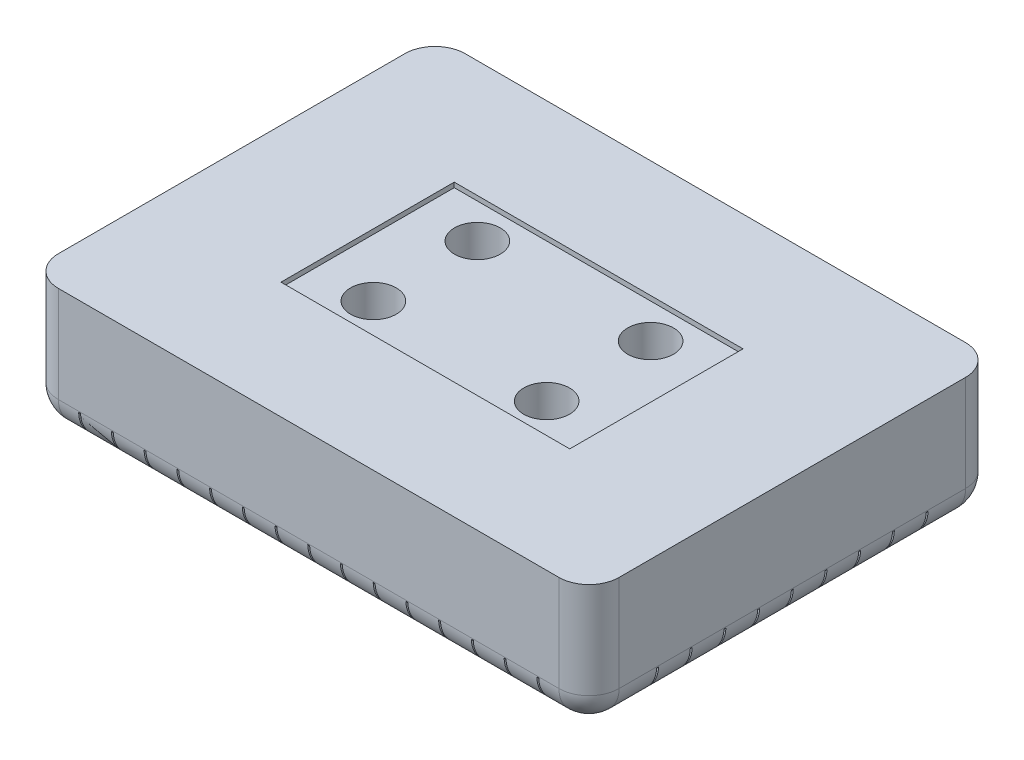
from build123d import *

# Parameters (mm, degrees)
SKETCH1_W             = 739.775
SKETCH1_H             = 536.575
BOSS_EXTRUDE1_DEPTH   = 166.6875
FILLET1_R             = 39.7002
CUT_EXTRUDE1_DEPTH    = 1.27
LPATTERN1_COUNT       = 8
LPATTERN1_PITCH       = 43.18
LPATTERN1_COL_COUNT   = 8
LPATTERN1_COL_PITCH   = 43.18
MIRROR1_COPY_1_DEPTH  = 1.27
MIRROR1_COPY_2_DEPTH  = 1.27
MIRROR1_COPY_3_DEPTH  = 1.27
MIRROR1_COPY_4_DEPTH  = 1.27
MIRROR1_COPY_5_DEPTH  = 1.27
MIRROR1_COPY_6_DEPTH  = 1.27
MIRROR1_COPY_7_DEPTH  = 1.27
MIRROR1_COPY_8_DEPTH  = 1.27
MIRROR1_COPY_9_DEPTH  = 1.27
MIRROR1_COPY_10_DEPTH = 1.27
MIRROR1_COPY_11_DEPTH = 1.27
MIRROR1_COPY_12_DEPTH = 1.27
MIRROR1_COPY_13_DEPTH = 1.27
MIRROR1_COPY_14_DEPTH = 1.27
CUT_EXTRUDE2_DEPTH    = 1.27
LPATTERN2_COUNT       = 5
LPATTERN2_PITCH       = 44.45
LPATTERN2_COL_COUNT   = 5
LPATTERN2_COL_PITCH   = 44.45
MIRROR2_COPY_1_DEPTH  = 1.27
MIRROR2_COPY_2_DEPTH  = 1.27
MIRROR2_COPY_3_DEPTH  = 1.27
MIRROR2_COPY_4_DEPTH  = 1.27
MIRROR2_COPY_5_DEPTH  = 1.27
MIRROR2_COPY_6_DEPTH  = 1.27
MIRROR2_COPY_7_DEPTH  = 1.27
MIRROR2_COPY_8_DEPTH  = 1.27
SKETCH4_R             = 30.1625
CUT_EXTRUDE3_DEPTH    = 167.6875
SKETCH5_W             = 381
SKETCH5_H             = 228.6
CUT_EXTRUDE4_DEPTH    = 6.35


with BuildPart() as part:
    # Sketch1 → Boss-Extrude1 (new body)
    with BuildSketch(Plane(origin=(0, 0, 0), x_dir=(1, 0, 0), z_dir=(0, 1, 0))):
        Rectangle(SKETCH1_W, SKETCH1_H)
    extrude(amount=BOSS_EXTRUDE1_DEPTH)

    # Fillet1
    fillet1_edges = [part.edges().sort_by_distance(p)[0] for p in [
        (0, 0, -268.2875),
        (369.8875, 0, 0),
        (0, 0, 268.2875),
        (-369.8875, 0, 0),
        (-369.8875, 83.34375, -268.2875),
        (369.8875, 83.34375, -268.2875),
        (369.8875, 83.34375, 268.2875),
        (-369.8875, 83.34375, 268.2875),
    ]]
    fillet(fillet1_edges, radius=FILLET1_R)

    # Sketch2 → Cut-Extrude1 (cut, symmetric)
    with BuildSketch(Plane(origin=(0, 0, 0), x_dir=(0, 0, -1), z_dir=(1, 0, 0))):
        with BuildLine():
            Line((279.4, 52.3875), (228.6, -11.1125))
            ThreePointArc((228.6, -11.1125), (264.521024484, 3.766475516), (279.4, 39.6875))
            Line((279.4, 39.6875), (279.4, 52.3875))
        make_face()
    cut_extrude1 = extrude(amount=CUT_EXTRUDE1_DEPTH, both=True, mode=Mode.SUBTRACT)

    # LPattern1: Cut-Extrude1 ×8
    with Locations(*[(i * LPATTERN1_PITCH, 0, 0) for i in range(1, LPATTERN1_COUNT)]):
        add(cut_extrude1, mode=Mode.SUBTRACT)

    # LPattern1 col: Cut-Extrude1 ×8
    with Locations(*[(-i * LPATTERN1_COL_PITCH, 0, 0) for i in range(1, LPATTERN1_COL_COUNT)]):
        add(cut_extrude1, mode=Mode.SUBTRACT)

    # Mirror1: Cut-Extrude1 across plane
    add(cut_extrude1.mirror(Plane.XY), mode=Mode.SUBTRACT)

    # Mirror1 copy 1 sketch → Mirror1 copy 1 (cut, symmetric)
    with BuildSketch(Plane(origin=(43.18, 0, 0), x_dir=(0, 0, 1), z_dir=(1, 0, 0))):
        with BuildLine():
            Line((279.4, -52.3875), (228.6, 11.1125))
            ThreePointArc((228.6, 11.1125), (264.521024484, -3.766475516), (279.4, -39.6875))
            Line((279.4, -39.6875), (279.4, -52.3875))
        make_face()
    extrude(amount=MIRROR1_COPY_1_DEPTH, both=True, mode=Mode.SUBTRACT)

    # Mirror1 copy 2 sketch → Mirror1 copy 2 (cut, symmetric)
    with BuildSketch(Plane(origin=(86.36, 0, 0), x_dir=(0, 0, 1), z_dir=(1, 0, 0))):
        with BuildLine():
            Line((279.4, -52.3875), (228.6, 11.1125))
            ThreePointArc((228.6, 11.1125), (264.521024484, -3.766475516), (279.4, -39.6875))
            Line((279.4, -39.6875), (279.4, -52.3875))
        make_face()
    extrude(amount=MIRROR1_COPY_2_DEPTH, both=True, mode=Mode.SUBTRACT)

    # Mirror1 copy 3 sketch → Mirror1 copy 3 (cut, symmetric)
    with BuildSketch(Plane(origin=(129.54, 0, 0), x_dir=(0, 0, 1), z_dir=(1, 0, 0))):
        with BuildLine():
            Line((279.4, -52.3875), (228.6, 11.1125))
            ThreePointArc((228.6, 11.1125), (264.521024484, -3.766475516), (279.4, -39.6875))
            Line((279.4, -39.6875), (279.4, -52.3875))
        make_face()
    extrude(amount=MIRROR1_COPY_3_DEPTH, both=True, mode=Mode.SUBTRACT)

    # Mirror1 copy 4 sketch → Mirror1 copy 4 (cut, symmetric)
    with BuildSketch(Plane(origin=(172.72, 0, 0), x_dir=(0, 0, 1), z_dir=(1, 0, 0))):
        with BuildLine():
            Line((279.4, -52.3875), (228.6, 11.1125))
            ThreePointArc((228.6, 11.1125), (264.521024484, -3.766475516), (279.4, -39.6875))
            Line((279.4, -39.6875), (279.4, -52.3875))
        make_face()
    extrude(amount=MIRROR1_COPY_4_DEPTH, both=True, mode=Mode.SUBTRACT)

    # Mirror1 copy 5 sketch → Mirror1 copy 5 (cut, symmetric)
    with BuildSketch(Plane(origin=(215.9, 0, 0), x_dir=(0, 0, 1), z_dir=(1, 0, 0))):
        with BuildLine():
            Line((279.4, -52.3875), (228.6, 11.1125))
            ThreePointArc((228.6, 11.1125), (264.521024484, -3.766475516), (279.4, -39.6875))
            Line((279.4, -39.6875), (279.4, -52.3875))
        make_face()
    extrude(amount=MIRROR1_COPY_5_DEPTH, both=True, mode=Mode.SUBTRACT)

    # Mirror1 copy 6 sketch → Mirror1 copy 6 (cut, symmetric)
    with BuildSketch(Plane(origin=(259.08, 0, 0), x_dir=(0, 0, 1), z_dir=(1, 0, 0))):
        with BuildLine():
            Line((279.4, -52.3875), (228.6, 11.1125))
            ThreePointArc((228.6, 11.1125), (264.521024484, -3.766475516), (279.4, -39.6875))
            Line((279.4, -39.6875), (279.4, -52.3875))
        make_face()
    extrude(amount=MIRROR1_COPY_6_DEPTH, both=True, mode=Mode.SUBTRACT)

    # Mirror1 copy 7 sketch → Mirror1 copy 7 (cut, symmetric)
    with BuildSketch(Plane(origin=(302.26, 0, 0), x_dir=(0, 0, 1), z_dir=(1, 0, 0))):
        with BuildLine():
            Line((279.4, -52.3875), (228.6, 11.1125))
            ThreePointArc((228.6, 11.1125), (264.521024484, -3.766475516), (279.4, -39.6875))
            Line((279.4, -39.6875), (279.4, -52.3875))
        make_face()
    extrude(amount=MIRROR1_COPY_7_DEPTH, both=True, mode=Mode.SUBTRACT)

    # Mirror1 copy 8 sketch → Mirror1 copy 8 (cut, symmetric)
    with BuildSketch(Plane(origin=(-43.18, 0, 0), x_dir=(0, 0, 1), z_dir=(1, 0, 0))):
        with BuildLine():
            Line((279.4, -52.3875), (228.6, 11.1125))
            ThreePointArc((228.6, 11.1125), (264.521024484, -3.766475516), (279.4, -39.6875))
            Line((279.4, -39.6875), (279.4, -52.3875))
        make_face()
    extrude(amount=MIRROR1_COPY_8_DEPTH, both=True, mode=Mode.SUBTRACT)

    # Mirror1 copy 9 sketch → Mirror1 copy 9 (cut, symmetric)
    with BuildSketch(Plane(origin=(-86.36, 0, 0), x_dir=(0, 0, 1), z_dir=(1, 0, 0))):
        with BuildLine():
            Line((279.4, -52.3875), (228.6, 11.1125))
            ThreePointArc((228.6, 11.1125), (264.521024484, -3.766475516), (279.4, -39.6875))
            Line((279.4, -39.6875), (279.4, -52.3875))
        make_face()
    extrude(amount=MIRROR1_COPY_9_DEPTH, both=True, mode=Mode.SUBTRACT)

    # Mirror1 copy 10 sketch → Mirror1 copy 10 (cut, symmetric)
    with BuildSketch(Plane(origin=(-129.54, 0, 0), x_dir=(0, 0, 1), z_dir=(1, 0, 0))):
        with BuildLine():
            Line((279.4, -52.3875), (228.6, 11.1125))
            ThreePointArc((228.6, 11.1125), (264.521024484, -3.766475516), (279.4, -39.6875))
            Line((279.4, -39.6875), (279.4, -52.3875))
        make_face()
    extrude(amount=MIRROR1_COPY_10_DEPTH, both=True, mode=Mode.SUBTRACT)

    # Mirror1 copy 11 sketch → Mirror1 copy 11 (cut, symmetric)
    with BuildSketch(Plane(origin=(-172.72, 0, 0), x_dir=(0, 0, 1), z_dir=(1, 0, 0))):
        with BuildLine():
            Line((279.4, -52.3875), (228.6, 11.1125))
            ThreePointArc((228.6, 11.1125), (264.521024484, -3.766475516), (279.4, -39.6875))
            Line((279.4, -39.6875), (279.4, -52.3875))
        make_face()
    extrude(amount=MIRROR1_COPY_11_DEPTH, both=True, mode=Mode.SUBTRACT)

    # Mirror1 copy 12 sketch → Mirror1 copy 12 (cut, symmetric)
    with BuildSketch(Plane(origin=(-215.9, 0, 0), x_dir=(0, 0, 1), z_dir=(1, 0, 0))):
        with BuildLine():
            Line((279.4, -52.3875), (228.6, 11.1125))
            ThreePointArc((228.6, 11.1125), (264.521024484, -3.766475516), (279.4, -39.6875))
            Line((279.4, -39.6875), (279.4, -52.3875))
        make_face()
    extrude(amount=MIRROR1_COPY_12_DEPTH, both=True, mode=Mode.SUBTRACT)

    # Mirror1 copy 13 sketch → Mirror1 copy 13 (cut, symmetric)
    with BuildSketch(Plane(origin=(-259.08, 0, 0), x_dir=(0, 0, 1), z_dir=(1, 0, 0))):
        with BuildLine():
            Line((279.4, -52.3875), (228.6, 11.1125))
            ThreePointArc((228.6, 11.1125), (264.521024484, -3.766475516), (279.4, -39.6875))
            Line((279.4, -39.6875), (279.4, -52.3875))
        make_face()
    extrude(amount=MIRROR1_COPY_13_DEPTH, both=True, mode=Mode.SUBTRACT)

    # Mirror1 copy 14 sketch → Mirror1 copy 14 (cut, symmetric)
    with BuildSketch(Plane(origin=(-302.26, 0, 0), x_dir=(0, 0, 1), z_dir=(1, 0, 0))):
        with BuildLine():
            Line((279.4, -52.3875), (228.6, 11.1125))
            ThreePointArc((228.6, 11.1125), (264.521024484, -3.766475516), (279.4, -39.6875))
            Line((279.4, -39.6875), (279.4, -52.3875))
        make_face()
    extrude(amount=MIRROR1_COPY_14_DEPTH, both=True, mode=Mode.SUBTRACT)

    # Sketch3 → Cut-Extrude2 (cut, symmetric)
    with BuildSketch(Plane.XY):
        with BuildLine():
            ThreePointArc((-330.2, -11.1125), (-366.121024484, 3.766475516), (-381, 39.6875))
            Line((-381, 39.6875), (-381, 52.3875))
            Line((-381, 52.3875), (-330.2, -11.1125))
        make_face()
    cut_extrude2 = extrude(amount=CUT_EXTRUDE2_DEPTH, both=True, mode=Mode.SUBTRACT)

    # LPattern2: Cut-Extrude2 ×5
    with Locations(*[(0, 0, -i * LPATTERN2_PITCH) for i in range(1, LPATTERN2_COUNT)]):
        add(cut_extrude2, mode=Mode.SUBTRACT)

    # LPattern2 col: Cut-Extrude2 ×5
    with Locations(*[(0, 0, i * LPATTERN2_COL_PITCH) for i in range(1, LPATTERN2_COL_COUNT)]):
        add(cut_extrude2, mode=Mode.SUBTRACT)

    # Mirror2: Cut-Extrude2 across plane
    add(cut_extrude2.mirror(Plane(origin=(0, 0, 0), x_dir=(0, 0, 1), z_dir=(1, 0, 0))), mode=Mode.SUBTRACT)

    # Mirror2 copy 1 sketch → Mirror2 copy 1 (cut, symmetric)
    with BuildSketch(Plane(origin=(0, 0, -44.45), x_dir=(-1, 0, 0), z_dir=(0, 0, 1))):
        with BuildLine():
            ThreePointArc((-330.2, 11.1125), (-366.121024484, -3.766475516), (-381, -39.6875))
            Line((-381, -39.6875), (-381, -52.3875))
            Line((-381, -52.3875), (-330.2, 11.1125))
        make_face()
    extrude(amount=MIRROR2_COPY_1_DEPTH, both=True, mode=Mode.SUBTRACT)

    # Mirror2 copy 2 sketch → Mirror2 copy 2 (cut, symmetric)
    with BuildSketch(Plane(origin=(0, 0, -88.9), x_dir=(-1, 0, 0), z_dir=(0, 0, 1))):
        with BuildLine():
            ThreePointArc((-330.2, 11.1125), (-366.121024484, -3.766475516), (-381, -39.6875))
            Line((-381, -39.6875), (-381, -52.3875))
            Line((-381, -52.3875), (-330.2, 11.1125))
        make_face()
    extrude(amount=MIRROR2_COPY_2_DEPTH, both=True, mode=Mode.SUBTRACT)

    # Mirror2 copy 3 sketch → Mirror2 copy 3 (cut, symmetric)
    with BuildSketch(Plane(origin=(0, 0, -133.35), x_dir=(-1, 0, 0), z_dir=(0, 0, 1))):
        with BuildLine():
            ThreePointArc((-330.2, 11.1125), (-366.121024484, -3.766475516), (-381, -39.6875))
            Line((-381, -39.6875), (-381, -52.3875))
            Line((-381, -52.3875), (-330.2, 11.1125))
        make_face()
    extrude(amount=MIRROR2_COPY_3_DEPTH, both=True, mode=Mode.SUBTRACT)

    # Mirror2 copy 4 sketch → Mirror2 copy 4 (cut, symmetric)
    with BuildSketch(Plane(origin=(0, 0, -177.8), x_dir=(-1, 0, 0), z_dir=(0, 0, 1))):
        with BuildLine():
            ThreePointArc((-330.2, 11.1125), (-366.121024484, -3.766475516), (-381, -39.6875))
            Line((-381, -39.6875), (-381, -52.3875))
            Line((-381, -52.3875), (-330.2, 11.1125))
        make_face()
    extrude(amount=MIRROR2_COPY_4_DEPTH, both=True, mode=Mode.SUBTRACT)

    # Mirror2 copy 5 sketch → Mirror2 copy 5 (cut, symmetric)
    with BuildSketch(Plane(origin=(0, 0, 44.45), x_dir=(-1, 0, 0), z_dir=(0, 0, 1))):
        with BuildLine():
            ThreePointArc((-330.2, 11.1125), (-366.121024484, -3.766475516), (-381, -39.6875))
            Line((-381, -39.6875), (-381, -52.3875))
            Line((-381, -52.3875), (-330.2, 11.1125))
        make_face()
    extrude(amount=MIRROR2_COPY_5_DEPTH, both=True, mode=Mode.SUBTRACT)

    # Mirror2 copy 6 sketch → Mirror2 copy 6 (cut, symmetric)
    with BuildSketch(Plane(origin=(0, 0, 88.9), x_dir=(-1, 0, 0), z_dir=(0, 0, 1))):
        with BuildLine():
            ThreePointArc((-330.2, 11.1125), (-366.121024484, -3.766475516), (-381, -39.6875))
            Line((-381, -39.6875), (-381, -52.3875))
            Line((-381, -52.3875), (-330.2, 11.1125))
        make_face()
    extrude(amount=MIRROR2_COPY_6_DEPTH, both=True, mode=Mode.SUBTRACT)

    # Mirror2 copy 7 sketch → Mirror2 copy 7 (cut, symmetric)
    with BuildSketch(Plane(origin=(0, 0, 133.35), x_dir=(-1, 0, 0), z_dir=(0, 0, 1))):
        with BuildLine():
            ThreePointArc((-330.2, 11.1125), (-366.121024484, -3.766475516), (-381, -39.6875))
            Line((-381, -39.6875), (-381, -52.3875))
            Line((-381, -52.3875), (-330.2, 11.1125))
        make_face()
    extrude(amount=MIRROR2_COPY_7_DEPTH, both=True, mode=Mode.SUBTRACT)

    # Mirror2 copy 8 sketch → Mirror2 copy 8 (cut, symmetric)
    with BuildSketch(Plane(origin=(0, 0, 177.8), x_dir=(-1, 0, 0), z_dir=(0, 0, 1))):
        with BuildLine():
            ThreePointArc((-330.2, 11.1125), (-366.121024484, -3.766475516), (-381, -39.6875))
            Line((-381, -39.6875), (-381, -52.3875))
            Line((-381, -52.3875), (-330.2, 11.1125))
        make_face()
    extrude(amount=MIRROR2_COPY_8_DEPTH, both=True, mode=Mode.SUBTRACT)

    # Sketch4 → Cut-Extrude3 (cut, through all)
    with BuildSketch(Plane(origin=(0, 166.6875, 0), x_dir=(1, 0, 0), z_dir=(0, 1, 0))):
        with Locations((-114.3, 68.58)):
            Circle(SKETCH4_R)
        with Locations((-114.3, -68.58)):
            Circle(SKETCH4_R)
        with Locations((114.3, 68.58)):
            Circle(SKETCH4_R)
        with Locations((114.3, -68.58)):
            Circle(SKETCH4_R)
    extrude(amount=-CUT_EXTRUDE3_DEPTH, mode=Mode.SUBTRACT)

    # Sketch5 → Cut-Extrude4 (cut)
    with BuildSketch(Plane(origin=(0, 166.6875, 0), x_dir=(1, 0, 0), z_dir=(0, 1, 0))):
        Rectangle(SKETCH5_W, SKETCH5_H)
    extrude(amount=-CUT_EXTRUDE4_DEPTH, mode=Mode.SUBTRACT)


solid = part.part
